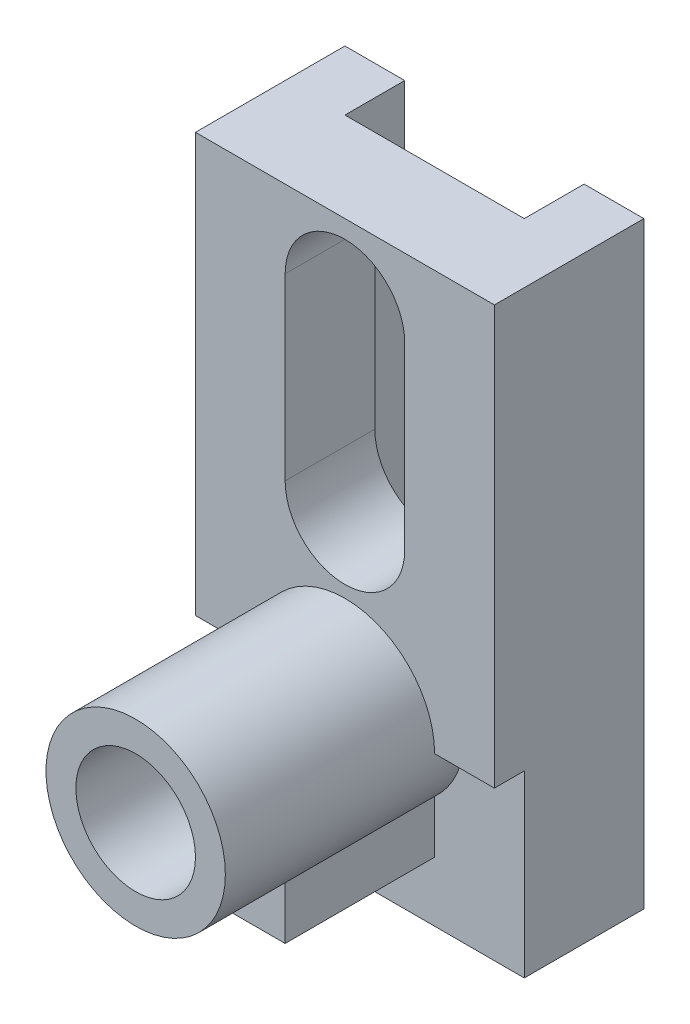
from build123d import *

# Parameters (mm, degrees)
IZIM1_W                     = 50
IZIM1_H                     = 100
Y_KSEKLIK_EKSTR_ZYON1_DEPTH = 60
IZIM2_R                     = 10
KES_EKSTR_ZYON2_DEPTH       = 35
IZIM3_R                     = 10
KES_EKSTR_ZYON3_DEPTH       = 35
KES_EKSTR_ZYON4_DEPTH       = 40
KES_EKSTR_ZYON5_DEPTH       = 15
IZIM7_R                     = 5
KES_EKSTR_ZYON6_DEPTH       = 8
IZIM8_W                     = 30
IZIM8_H                     = 10
KES_EKSTR_ZYON7_DEPTH       = 101


with BuildPart() as part:
    # Çizim1 → Yükseklik-Ekstrüzyon1 (new body)
    with BuildSketch(Plane.XY):
        with Locations((25, 50)):
            Rectangle(IZIM1_W, IZIM1_H)
    extrude(amount=Y_KSEKLIK_EKSTR_ZYON1_DEPTH)

    # Çizim2 → Kes-Ekstrüzyon2 (cut)
    with BuildSketch(Plane.XY.offset(60)):
        with BuildLine():
            Line((0, 100), (0, 30))
            Line((0, 30), (10, 30))
            ThreePointArc((10, 30), (25, 45), (40, 30))
            Line((40, 30), (50, 30))
            Line((50, 30), (50, 100))
            Line((50, 100), (0, 100))
        make_face()
        with Locations((25, 30)):
            Circle(IZIM2_R)
    extrude(amount=-KES_EKSTR_ZYON2_DEPTH, mode=Mode.SUBTRACT)

    # Çizim3 → Kes-Ekstrüzyon3 (cut)
    with BuildSketch(Plane.XY.offset(25)):
        with Locations((25, 30)):
            Circle(IZIM3_R)
        with BuildLine():
            Line((15, 57), (15, 87))
            ThreePointArc((15, 87), (25, 97), (35, 87))
            Line((35, 87), (35, 57))
            ThreePointArc((35, 57), (25, 47), (15, 57))
        make_face()
    extrude(amount=-KES_EKSTR_ZYON3_DEPTH, mode=Mode.SUBTRACT)

    # Çizim5 → Kes-Ekstrüzyon4 (cut)
    with BuildSketch(Plane.XY.offset(60)):
        with BuildLine():
            Line((35, 10), (15, 10))
            Line((15, 10), (15, 18.819660113))
            ThreePointArc((15, 18.819660113), (11.306936062, 23.876275643), (10, 30))
            Line((10, 30), (0, 30))
            Line((0, 30), (0, 0))
            Line((0, 0), (50, 0))
            Line((50, 0), (50, 30))
            Line((50, 30), (40, 30))
            ThreePointArc((40, 30), (38.693063938, 23.876275643), (35, 18.819660113))
            Line((35, 18.819660113), (35, 10))
        make_face()
    extrude(amount=-KES_EKSTR_ZYON4_DEPTH, mode=Mode.SUBTRACT)

    # Çizim6 → Kes-Ekstrüzyon5 (cut)
    with BuildSketch(Plane.XY.offset(60)):
        with BuildLine():
            Line((15, 18.819660113), (15, 10))
            Line((15, 10), (35, 10))
            Line((35, 10), (35, 18.819660113))
            ThreePointArc((35, 18.819660113), (25, 15), (15, 18.819660113))
        make_face()
    extrude(amount=-KES_EKSTR_ZYON5_DEPTH, mode=Mode.SUBTRACT)

    # Çizim7 → Kes-Ekstrüzyon6 (cut)
    with BuildSketch(Plane.XZ.offset(-10)):
        with Locations((25, 35)):
            Circle(IZIM7_R)
    extrude(amount=-KES_EKSTR_ZYON6_DEPTH, mode=Mode.SUBTRACT)

    # Çizim8 → Kes-Ekstrüzyon7 (cut, through all)
    with BuildSketch(Plane.XZ):
        with Locations((25, 5)):
            Rectangle(IZIM8_W, IZIM8_H)
    extrude(amount=-KES_EKSTR_ZYON7_DEPTH, mode=Mode.SUBTRACT)


solid = part.part
